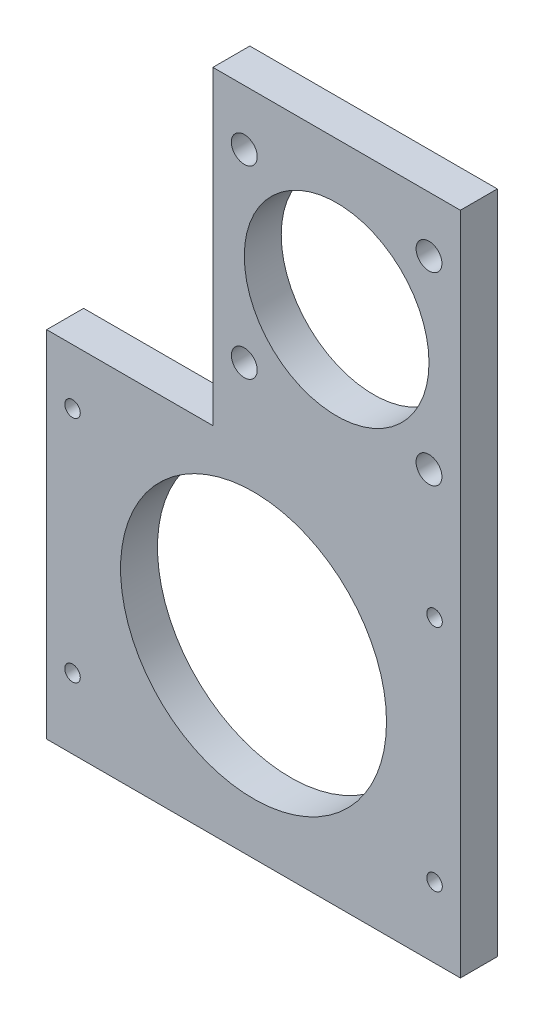
from build123d import *

# Parameters (mm, degrees)
SKETCH_1_R             = 36
SKETCH_1_R_2           = 25
EXTRUDE_1_DEPTH        = 10
HOLE_WIZARD_M5_1_D     = 4.2
HOLE_WIZARD_M5_1_DEPTH = 12.4
HOLE_WIZARD_M5_1_TIP   = 1.2618073
MM_1_D                 = 7
MM_1_DEPTH             = 12.4
MM_1_TIP               = 2.103012167


with BuildPart() as part:
    # 草图1 → 凸台-拉伸1 (new body)
    with BuildSketch(Plane.XY):
        Polygon((-11, 90), (56, 90), (56, -90), (-56, -90), (-56, 6), (-11, 6), align=None)
        with Locations((0, -40)):
            Circle(SKETCH_1_R, mode=Mode.SUBTRACT)
        with Locations((22.5, 50)):
            Circle(SKETCH_1_R_2, mode=Mode.SUBTRACT)
    extrude(amount=EXTRUDE_1_DEPTH)

    # M5 螺纹孔1
    with Locations(Plane(origin=(49, -9, 0), x_dir=(-1, 0, 0), z_dir=(0, 0, -1))):
        with Locations((0, 0), (98, 0), (98, -62), (0, -62)):
            Hole(HOLE_WIZARD_M5_1_D / 2, depth=HOLE_WIZARD_M5_1_DEPTH)
            with Locations((0, 0, -(HOLE_WIZARD_M5_1_DEPTH + HOLE_WIZARD_M5_1_TIP / 2))):  # 118° drill point
                Cone(0, HOLE_WIZARD_M5_1_D / 2, HOLE_WIZARD_M5_1_TIP, mode=Mode.SUBTRACT)

    # 大小mm 暗销槽口1
    with Locations(Plane(origin=(47.5, 25, 0), x_dir=(-1, 0, 0), z_dir=(0, 0, -1))):
        with Locations((0, 0), (0, 50), (50, 50), (50, 0)):
            Hole(MM_1_D / 2, depth=MM_1_DEPTH)
            with Locations((0, 0, -(MM_1_DEPTH + MM_1_TIP / 2))):  # 118° drill point
                Cone(0, MM_1_D / 2, MM_1_TIP, mode=Mode.SUBTRACT)


solid = part.part
